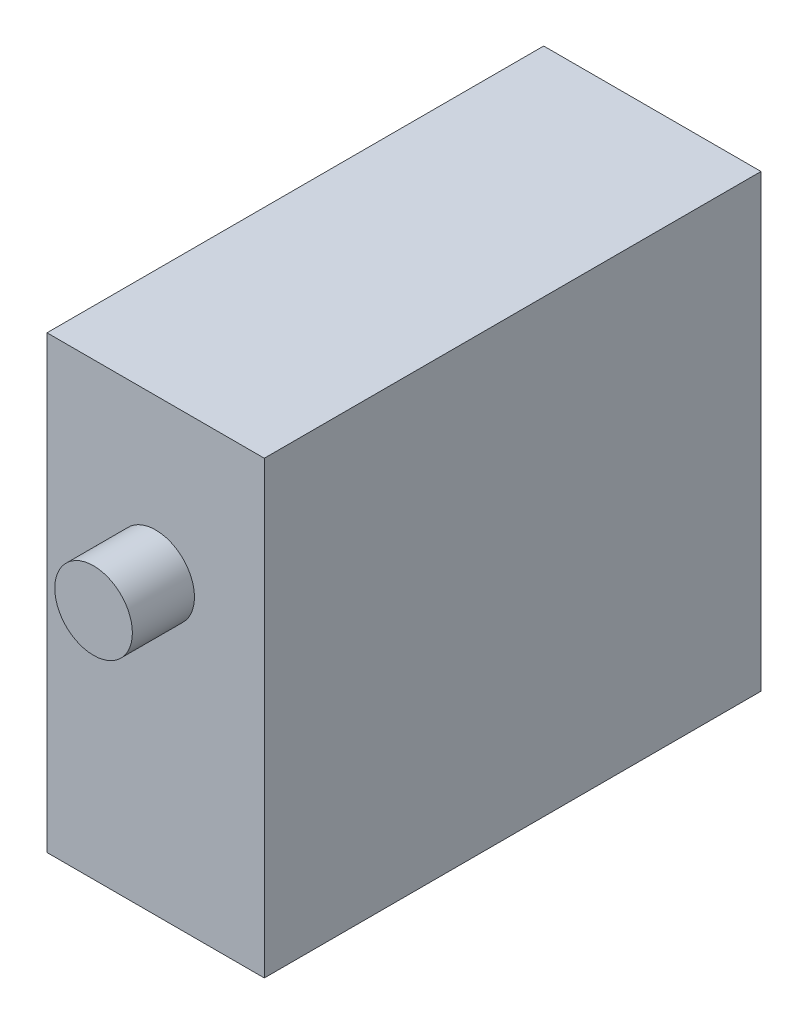
from build123d import *

# Parameters (mm, degrees)
SKETCH1_W           = 14
SKETCH1_H           = 29
BOSS_EXTRUDE1_DEPTH = 32
SKETCH2_R           = 2.5
BOSS_EXTRUDE2_DEPTH = 4


with BuildPart() as part:
    # Sketch1 → Boss-Extrude1 (new body)
    with BuildSketch(Plane.XY):
        Rectangle(SKETCH1_W, SKETCH1_H)
    extrude(amount=BOSS_EXTRUDE1_DEPTH)

    # Sketch2 → Boss-Extrude2 (add)
    with BuildSketch(Plane.XY.offset(32)):
        with Locations((0, 4.5)):
            Circle(SKETCH2_R)
    extrude(amount=BOSS_EXTRUDE2_DEPTH)


solid = part.part
